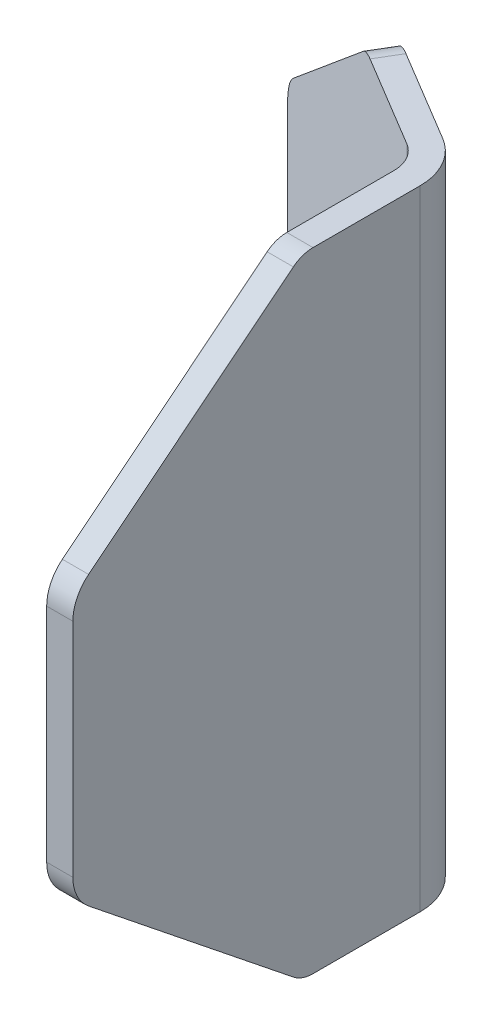
from build123d import *

# Parameters (mm, degrees)
BOSS_EXTRUDE2_DEPTH = 76.2
CUT_EXTRUDE3_REACH  = 43.301
CUT_EXTRUDE4_REACH  = 62.908
FILLET1_R           = 5.08
FILLET2_R           = 3.81


with BuildPart() as part:
    # Sketch1 → Boss-Extrude2 (new body)
    with BuildSketch(Plane(origin=(0, 0, 0), x_dir=(1, 0, 0), z_dir=(0, 1, 0))):
        with BuildLine():
            Line((-39.668156778, 23.786852448), (-3.577868638, 2.145454699))
            ThreePointArc((-3.577868638, 2.145454699), (-0.956579917, -0.541770779), (0, -4.171824524))
            Line((0, -4.171824524), (0, -46.2534))
            Line((0, -46.2534), (-3.175, -46.2534))
            Line((-3.175, -46.2534), (-3.175, -4.171824524))
            ThreePointArc((-3.175, -4.171824524), (-3.719260987, -2.106449117), (-5.21068388, -0.577510483))
            Line((-5.21068388, -0.577510483), (-41.300972021, 21.063887265))
            Line((-41.300972021, 21.063887265), (-39.668156778, 23.786852448))
        make_face()
    extrude(amount=BOSS_EXTRUDE2_DEPTH)

    # Sketch2 → Cut-Extrude3 (cut, up to next)
    with BuildSketch(Plane(origin=(0, 0, 0), x_dir=(0, 0, -1), z_dir=(1, 0, 0)), mode=Mode.PRIVATE) as cut_extrude3_sk1:
        Polygon((-46.2534, 53.975), (-18.494383897, 76.2), (-46.2534, 76.2), align=None)
    cut_extrude3_tool1 = extrude(cut_extrude3_sk1.sketch, amount=-CUT_EXTRUDE3_REACH, mode=Mode.PRIVATE) & part.part
    add(cut_extrude3_tool1.solids().sort_by_distance((0, 68.791667, 37.000395))[0], mode=Mode.SUBTRACT)
    # Sketch2 → Cut-Extrude3 (cut, up to next)
    with BuildSketch(Plane(origin=(0, 0, 0), x_dir=(0, 0, -1), z_dir=(1, 0, 0)), mode=Mode.PRIVATE) as cut_extrude3_sk2:
        Polygon((-46.2534, 22.225), (-46.2534, 0), (-18.494383897, 0), align=None)
    cut_extrude3_tool2 = extrude(cut_extrude3_sk2.sketch, amount=-CUT_EXTRUDE3_REACH, mode=Mode.PRIVATE) & part.part
    add(cut_extrude3_tool2.solids().sort_by_distance((0, 7.408333, 37.000395))[0], mode=Mode.SUBTRACT)

    # Sketch4 → Cut-Extrude4 (cut, up to next)
    with BuildSketch(Plane(origin=(0, 0, 0), x_dir=(-0.857626829, 0, -0.514272517), z_dir=(0.514272517, 0, -0.857626829)), mode=Mode.PRIVATE) as cut_extrude4_sk1:
        Polygon((46.2534, 53.975), (18.494383897, 76.2), (46.2534, 76.2), align=None)
    cut_extrude4_tool1 = extrude(cut_extrude4_sk1.sketch, amount=-CUT_EXTRUDE4_REACH, mode=Mode.PRIVATE) & part.part
    add(cut_extrude4_tool1.solids().sort_by_distance((-31.732531, 68.791667, -19.028286))[0], mode=Mode.SUBTRACT)
    # Sketch4 → Cut-Extrude4 (cut, up to next)
    with BuildSketch(Plane(origin=(0, 0, 0), x_dir=(-0.857626829, 0, -0.514272517), z_dir=(0.514272517, 0, -0.857626829)), mode=Mode.PRIVATE) as cut_extrude4_sk2:
        Polygon((18.494383897, 0), (46.2534, 22.225), (46.2534, 0), align=None)
    cut_extrude4_tool2 = extrude(cut_extrude4_sk2.sketch, amount=-CUT_EXTRUDE4_REACH, mode=Mode.PRIVATE) & part.part
    add(cut_extrude4_tool2.solids().sort_by_distance((-31.732531, 7.408333, -19.028286))[0], mode=Mode.SUBTRACT)

    # Fillet1
    fillet1_edges = [part.edges().sort_by_distance(p)[0] for p in [
        (-1.5875, 22.225, 46.2534),
        (-1.5875, 53.975, 46.2534),
        (-40.4845644, 22.225, -22.425369856),
        (-40.4845644, 53.975, -22.425369856),
    ]]
    fillet(fillet1_edges, radius=FILLET1_R)

    # Fillet2
    fillet2_edges = [part.edges().sort_by_distance(p)[0] for p in [
        (-1.5875, 0, 18.494383897),
        (-1.5875, 76.2, 18.494383897),
        (-16.677687439, 0, -8.14967077),
        (-16.677687439, 76.2, -8.14967077),
    ]]
    fillet(fillet2_edges, radius=FILLET2_R)


solid = part.part
